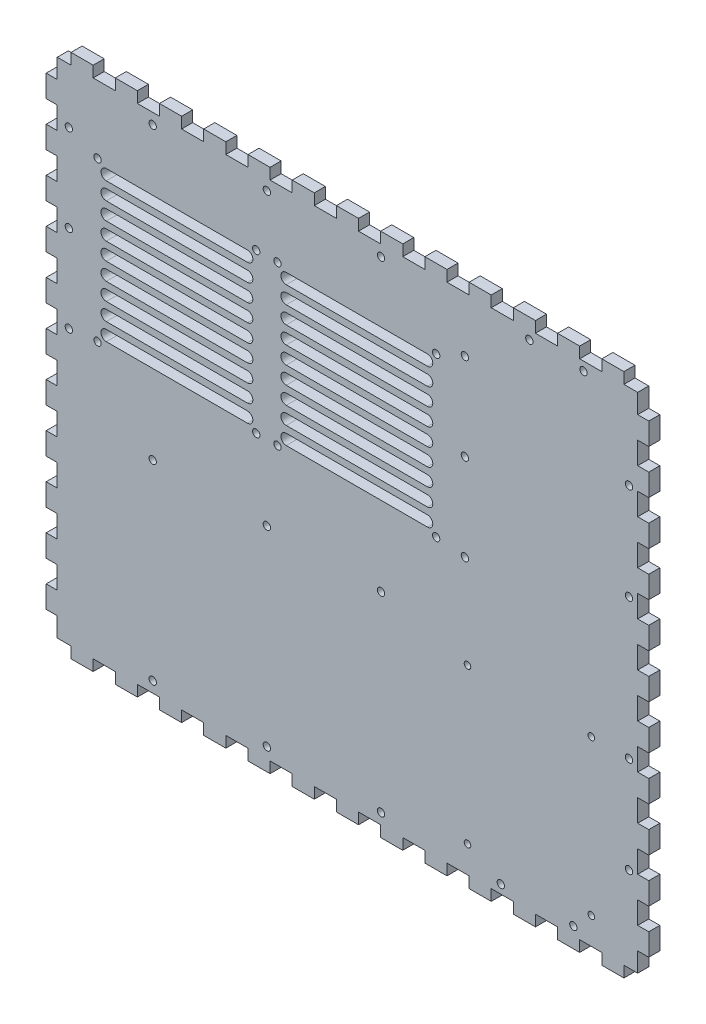
from build123d import *

# Parameters (mm, degrees)
BOSS_EXTRUDE1_DEPTH   = 5.715
F_6_CLEARANCE_HOLE1_D = 3.7973
CUT_EXTRUDE1_DEPTH    = 10
F_6_CLEARANCE_HOLE2_D = 3.7973
M3_CLEARANCE_HOLE1_D  = 3.4


with BuildPart() as part:
    # Model → Boss-Extrude1 (new body)
    with BuildSketch(Plane.XY):
        Polygon((644.691, 28.5722), (651.813, 28.5722), (651.813, 22.8575), (663.247, 22.8575), (663.247, 28.5722), (674.673, 28.5722), (674.673, 22.8575), (686.103, 22.8575), (686.103, 28.5722), (697.537, 28.5722), (697.537, 22.8575), (708.963, 22.8575), (708.963, 28.5722), (720.397, 28.5722), (720.397, 22.8575), (731.823, 22.8575), (731.823, 28.5722), (743.253, 28.5722), (743.253, 22.8575), (754.687, 22.8575), (754.687, 28.5722), (766.113, 28.5722), (766.113, 22.8575), (777.547, 22.8575), (777.547, 28.5722), (788.973, 28.5722), (788.973, 22.8575), (800.403, 22.8575), (800.403, 28.5722), (811.837, 28.5722), (811.837, 22.8575), (823.263, 22.8575), (823.263, 28.5722), (834.697, 28.5722), (834.697, 22.8575), (846.123, 22.8575), (846.123, 28.5722), (857.553, 28.5722), (857.553, 22.8575), (868.987, 22.8575), (868.987, 28.5722), (880.413, 28.5722), (880.413, 22.8575), (891.847, 22.8575), (891.847, 28.5722), (903.273, 28.5722), (903.273, 22.8575), (914.703, 22.8575), (914.703, 28.5722), (926.137, 28.5722), (926.137, 22.8575), (937.563, 22.8575), (937.563, 28.5722), (944.69, 28.5722), (944.69, 38.5576), (950.405, 38.5576), (950.405, 49.9868), (944.69, 49.9868), (944.69, 61.4179), (950.405, 61.4179), (950.405, 72.8472), (944.69, 72.8472), (944.69, 84.2779), (950.405, 84.2779), (950.405, 95.7076), (944.69, 95.7076), (944.69, 107.137), (950.405, 107.137), (950.405, 118.568), (944.69, 118.568), (944.69, 129.997), (950.405, 129.997), (950.405, 141.428), (944.69, 141.428), (944.69, 152.858), (950.405, 152.858), (950.405, 164.287), (944.69, 164.287), (944.69, 175.718), (950.405, 175.718), (950.405, 187.147), (944.69, 187.147), (944.69, 198.578), (950.405, 198.578), (950.405, 210.008), (944.69, 210.008), (944.69, 221.437), (950.405, 221.437), (950.405, 232.868), (944.69, 232.868), (944.69, 244.297), (950.405, 244.297), (950.405, 255.728), (944.69, 255.728), (944.69, 267.158), (950.405, 267.158), (950.405, 278.587), (944.69, 278.587), (944.69, 288.572), (937.563, 288.572), (937.563, 294.287), (926.137, 294.287), (926.137, 288.572), (914.703, 288.572), (914.703, 294.287), (903.273, 294.287), (903.273, 288.572), (891.847, 288.572), (891.847, 294.287), (880.413, 294.287), (880.413, 288.572), (868.987, 288.572), (868.987, 294.287), (857.553, 294.287), (857.553, 288.572), (846.123, 288.572), (846.123, 294.287), (834.697, 294.287), (834.697, 288.572), (823.263, 288.572), (823.263, 294.287), (811.837, 294.287), (811.837, 288.572), (800.403, 288.572), (800.403, 294.287), (788.973, 294.287), (788.973, 288.572), (777.547, 288.572), (777.547, 294.287), (766.113, 294.287), (766.113, 288.572), (754.687, 288.572), (754.687, 294.287), (743.253, 294.287), (743.253, 288.572), (731.823, 288.572), (731.823, 294.287), (720.397, 294.287), (720.397, 288.572), (708.963, 288.572), (708.963, 294.287), (697.537, 294.287), (697.537, 288.572), (686.103, 288.572), (686.103, 294.287), (674.673, 294.287), (674.673, 288.572), (663.247, 288.572), (663.247, 294.287), (651.813, 294.287), (651.813, 288.572), (644.691, 288.572), (644.691, 278.587), (638.976, 278.587), (638.976, 267.158), (644.691, 267.158), (644.691, 255.728), (638.976, 255.728), (638.976, 244.297), (644.691, 244.297), (644.691, 232.868), (638.976, 232.868), (638.976, 221.437), (644.691, 221.437), (644.691, 210.008), (638.976, 210.008), (638.976, 198.578), (644.691, 198.578), (644.691, 187.147), (638.976, 187.147), (638.976, 175.718), (644.691, 175.718), (644.691, 164.287), (638.976, 164.287), (638.976, 152.858), (644.691, 152.858), (644.691, 141.428), (638.976, 141.428), (638.976, 129.997), (644.691, 129.997), (644.691, 118.568), (638.976, 118.568), (638.976, 107.137), (644.691, 107.137), (644.691, 95.7076), (638.976, 95.7076), (638.976, 84.2779), (644.691, 84.2779), (644.691, 72.8472), (638.976, 72.8472), (638.976, 61.4179), (644.691, 61.4179), (644.691, 49.9868), (638.976, 49.9868), (638.976, 38.5576), (644.691, 38.5576), align=None)
    extrude(amount=BOSS_EXTRUDE1_DEPTH)

    # #6 Clearance Hole1 (through all)
    with Locations(Plane.XY.offset(5.715)):
        with Locations((665.53225, 253.6719), (747.53225, 253.6719), (758.53225, 253.6719), (840.53225, 253.6719), (840.53225, 171.6719), (758.53225, 171.6719), (747.53225, 171.6719), (665.53225, 171.6719)):
            Hole(F_6_CLEARANCE_HOLE1_D / 2)

    # Sketch1 → Cut-Extrude1 (cut)
    with BuildSketch(Plane(origin=(0, 0, 0), x_dir=(-1, 0, 0), z_dir=(0, 0, -1))):
        with BuildLine():
            Line((-836.03225, 251.4219), (-763.03225, 251.4219))
            ThreePointArc((-763.03225, 251.4219), (-760.28225, 248.6719), (-763.03225, 245.9219))
            Line((-763.03225, 245.9219), (-836.03225, 245.9219))
            ThreePointArc((-836.03225, 245.9219), (-838.78225, 248.6719), (-836.03225, 251.4219))
        make_face()
        with BuildLine():
            Line((-836.03225, 236.9219), (-763.03225, 236.9219))
            ThreePointArc((-763.03225, 236.9219), (-760.28225, 239.6719), (-763.03225, 242.4219))
            Line((-763.03225, 242.4219), (-836.03225, 242.4219))
            ThreePointArc((-836.03225, 242.4219), (-838.78225, 239.6719), (-836.03225, 236.9219))
        make_face()
        with BuildLine():
            Line((-836.03225, 227.9219), (-763.03225, 227.9219))
            ThreePointArc((-763.03225, 227.9219), (-760.28225, 230.6719), (-763.03225, 233.4219))
            Line((-763.03225, 233.4219), (-836.03225, 233.4219))
            ThreePointArc((-836.03225, 233.4219), (-838.78225, 230.6719), (-836.03225, 227.9219))
        make_face()
        with BuildLine():
            Line((-836.03225, 218.9219), (-763.03225, 218.9219))
            ThreePointArc((-763.03225, 218.9219), (-760.28225, 221.6719), (-763.03225, 224.4219))
            Line((-763.03225, 224.4219), (-836.03225, 224.4219))
            ThreePointArc((-836.03225, 224.4219), (-838.78225, 221.6719), (-836.03225, 218.9219))
        make_face()
        with BuildLine():
            Line((-836.03225, 209.9219), (-763.03225, 209.9219))
            ThreePointArc((-763.03225, 209.9219), (-760.28225, 212.6719), (-763.03225, 215.4219))
            Line((-763.03225, 215.4219), (-836.03225, 215.4219))
            ThreePointArc((-836.03225, 215.4219), (-838.78225, 212.6719), (-836.03225, 209.9219))
        make_face()
        with BuildLine():
            Line((-836.03225, 200.9219), (-763.03225, 200.9219))
            ThreePointArc((-763.03225, 200.9219), (-760.28225, 203.6719), (-763.03225, 206.4219))
            Line((-763.03225, 206.4219), (-836.03225, 206.4219))
            ThreePointArc((-836.03225, 206.4219), (-838.78225, 203.6719), (-836.03225, 200.9219))
        make_face()
        with BuildLine():
            Line((-836.03225, 191.9219), (-763.03225, 191.9219))
            ThreePointArc((-763.03225, 191.9219), (-760.28225, 194.6719), (-763.03225, 197.4219))
            Line((-763.03225, 197.4219), (-836.03225, 197.4219))
            ThreePointArc((-836.03225, 197.4219), (-838.78225, 194.6719), (-836.03225, 191.9219))
        make_face()
        with BuildLine():
            Line((-836.03225, 182.9219), (-763.03225, 182.9219))
            ThreePointArc((-763.03225, 182.9219), (-760.28225, 185.6719), (-763.03225, 188.4219))
            Line((-763.03225, 188.4219), (-836.03225, 188.4219))
            ThreePointArc((-836.03225, 188.4219), (-838.78225, 185.6719), (-836.03225, 182.9219))
        make_face()
        with BuildLine():
            Line((-836.03225, 173.9219), (-763.03225, 173.9219))
            ThreePointArc((-763.03225, 173.9219), (-760.28225, 176.6719), (-763.03225, 179.4219))
            Line((-763.03225, 179.4219), (-836.03225, 179.4219))
            ThreePointArc((-836.03225, 179.4219), (-838.78225, 176.6719), (-836.03225, 173.9219))
        make_face()
        with BuildLine():
            Line((-670.03225, 179.4219), (-743.03225, 179.4219))
            ThreePointArc((-743.03225, 179.4219), (-745.78225, 176.6719), (-743.03225, 173.9219))
            Line((-743.03225, 173.9219), (-670.03225, 173.9219))
            ThreePointArc((-670.03225, 173.9219), (-667.28225, 176.6719), (-670.03225, 179.4219))
        make_face()
        with BuildLine():
            Line((-670.03225, 188.4219), (-743.03225, 188.4219))
            ThreePointArc((-743.03225, 188.4219), (-745.78225, 185.6719), (-743.03225, 182.9219))
            Line((-743.03225, 182.9219), (-670.03225, 182.9219))
            ThreePointArc((-670.03225, 182.9219), (-667.28225, 185.6719), (-670.03225, 188.4219))
        make_face()
        with BuildLine():
            Line((-670.03225, 197.4219), (-743.03225, 197.4219))
            ThreePointArc((-743.03225, 197.4219), (-745.78225, 194.6719), (-743.03225, 191.9219))
            Line((-743.03225, 191.9219), (-670.03225, 191.9219))
            ThreePointArc((-670.03225, 191.9219), (-667.28225, 194.6719), (-670.03225, 197.4219))
        make_face()
        with BuildLine():
            Line((-670.03225, 206.4219), (-743.03225, 206.4219))
            ThreePointArc((-743.03225, 206.4219), (-745.78225, 203.6719), (-743.03225, 200.9219))
            Line((-743.03225, 200.9219), (-670.03225, 200.9219))
            ThreePointArc((-670.03225, 200.9219), (-667.28225, 203.6719), (-670.03225, 206.4219))
        make_face()
        with BuildLine():
            Line((-670.03225, 215.4219), (-743.03225, 215.4219))
            ThreePointArc((-743.03225, 215.4219), (-745.78225, 212.6719), (-743.03225, 209.9219))
            Line((-743.03225, 209.9219), (-670.03225, 209.9219))
            ThreePointArc((-670.03225, 209.9219), (-667.28225, 212.6719), (-670.03225, 215.4219))
        make_face()
        with BuildLine():
            Line((-670.03225, 224.4219), (-743.03225, 224.4219))
            ThreePointArc((-743.03225, 224.4219), (-745.78225, 221.6719), (-743.03225, 218.9219))
            Line((-743.03225, 218.9219), (-670.03225, 218.9219))
            ThreePointArc((-670.03225, 218.9219), (-667.28225, 221.6719), (-670.03225, 224.4219))
        make_face()
        with BuildLine():
            Line((-670.03225, 233.4219), (-743.03225, 233.4219))
            ThreePointArc((-743.03225, 233.4219), (-745.78225, 230.6719), (-743.03225, 227.9219))
            Line((-743.03225, 227.9219), (-670.03225, 227.9219))
            ThreePointArc((-670.03225, 227.9219), (-667.28225, 230.6719), (-670.03225, 233.4219))
        make_face()
        with BuildLine():
            Line((-670.03225, 242.4219), (-743.03225, 242.4219))
            ThreePointArc((-743.03225, 242.4219), (-745.78225, 239.6719), (-743.03225, 236.9219))
            Line((-743.03225, 236.9219), (-670.03225, 236.9219))
            ThreePointArc((-670.03225, 236.9219), (-667.28225, 239.6719), (-670.03225, 242.4219))
        make_face()
        with BuildLine():
            Line((-670.03225, 251.4219), (-743.03225, 251.4219))
            ThreePointArc((-743.03225, 251.4219), (-745.78225, 248.6719), (-743.03225, 245.9219))
            Line((-743.03225, 245.9219), (-670.03225, 245.9219))
            ThreePointArc((-670.03225, 245.9219), (-667.28225, 248.6719), (-670.03225, 251.4219))
        make_face()
    extrude(amount=-CUT_EXTRUDE1_DEPTH, mode=Mode.SUBTRACT)

    # #6 Clearance Hole2 (through all)
    with Locations(Plane.XY.offset(5.715)):
        with Locations((694.03225, 282.9467), (753.03225, 282.9467), (812.03225, 282.9467), (855.3735, 260.12195), (888.69, 284.072), (916.69, 284.072), (940.19, 244.6429375), (940.19, 194.7848125), (855.3735, 215.12195), (855.3735, 170.12195), (650.691, 260.12195), (650.691, 215.12195), (650.691, 170.12195), (694.03225, 132.9469), (753.03225, 132.9469), (812.03225, 132.9469), (940.19, 122.3593875), (940.19, 72.5012625), (911.44, 33.0722), (873.94, 33.0722), (812.03225, 34.1972), (753.03225, 34.1972), (694.03225, 34.1972)):
            Hole(F_6_CLEARANCE_HOLE2_D / 2)

    # M3 Clearance Hole1 (through all)
    with Locations(Plane(origin=(0, 0, 0), x_dir=(-1, 0, 0), z_dir=(0, 0, -1))):
        with Locations((-856.726, 122.4469), (-920.726, 122.4469), (-920.726, 42.4469), (-856.726, 42.4469)):
            Hole(M3_CLEARANCE_HOLE1_D / 2)


solid = part.part
